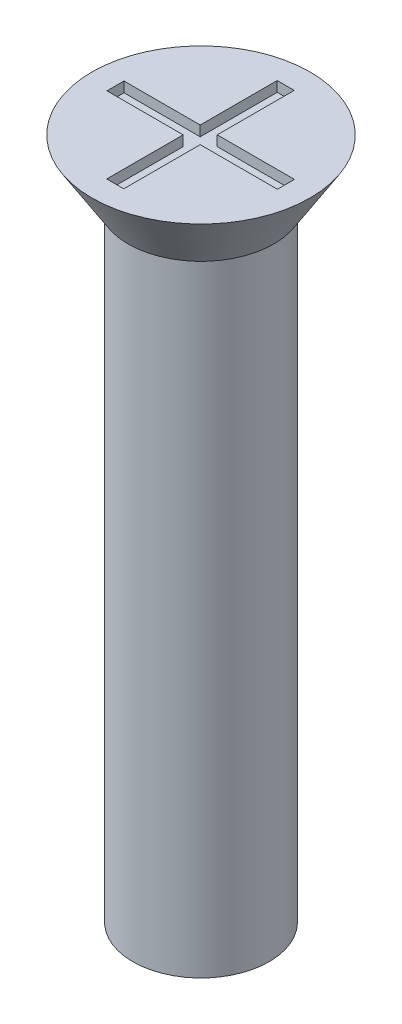
from build123d import *

# Parameters (mm, degrees)
SKETCH1_R           = 2
BOSS_EXTRUDE1_DEPTH = 20
SKETCH2_R           = 3.2
BOSS_EXTRUDE2_DEPTH = 1.7
BOSS_EXTRUDE2_TAPER = 32
SKETCH3_W           = 0.5
SKETCH3_H           = 2.258378485
SKETCH3_H_2         = 2.241621515
SKETCH3_W_2         = 2.234727157
SKETCH3_H_3         = 0.5
SKETCH3_W_3         = 2.265272843
CUT_EXTRUDE1_DEPTH  = 0.3


with BuildPart() as part:
    # Sketch1 → Boss-Extrude1 (new body)
    with BuildSketch(Plane(origin=(0, 0, 0), x_dir=(1, 0, 0), z_dir=(0, 1, 0))):
        Circle(SKETCH1_R)
    extrude(amount=BOSS_EXTRUDE1_DEPTH)

    # Sketch2 → Boss-Extrude2 (add)
    with BuildSketch(Plane(origin=(0, 20, 0), x_dir=(1, 0, 0), z_dir=(0, 1, 0))):
        Circle(SKETCH2_R)
    extrude(amount=-BOSS_EXTRUDE2_DEPTH, taper=BOSS_EXTRUDE2_TAPER)

    # Sketch3 → Cut-Extrude1 (cut)
    with BuildSketch(Plane(origin=(0, 20, 0), x_dir=(1, 0, 0), z_dir=(0, 1, 0))):
        with Locations((-0.015272843, 1.370810757)):
            Rectangle(SKETCH3_W, SKETCH3_H)
        with Locations((-0.015272843, -1.379189243)):
            Rectangle(SKETCH3_W, SKETCH3_H_2)
        with Locations((-1.382636421, -0.008378485)):
            Rectangle(SKETCH3_W_2, SKETCH3_H_3)
        with Locations((1.367363579, -0.008378485)):
            Rectangle(SKETCH3_W_3, SKETCH3_H_3)
        with Locations((-0.015272843, -0.008378485)):
            Rectangle(SKETCH3_W, SKETCH3_H_3)
    extrude(amount=-CUT_EXTRUDE1_DEPTH, mode=Mode.SUBTRACT)


solid = part.part
